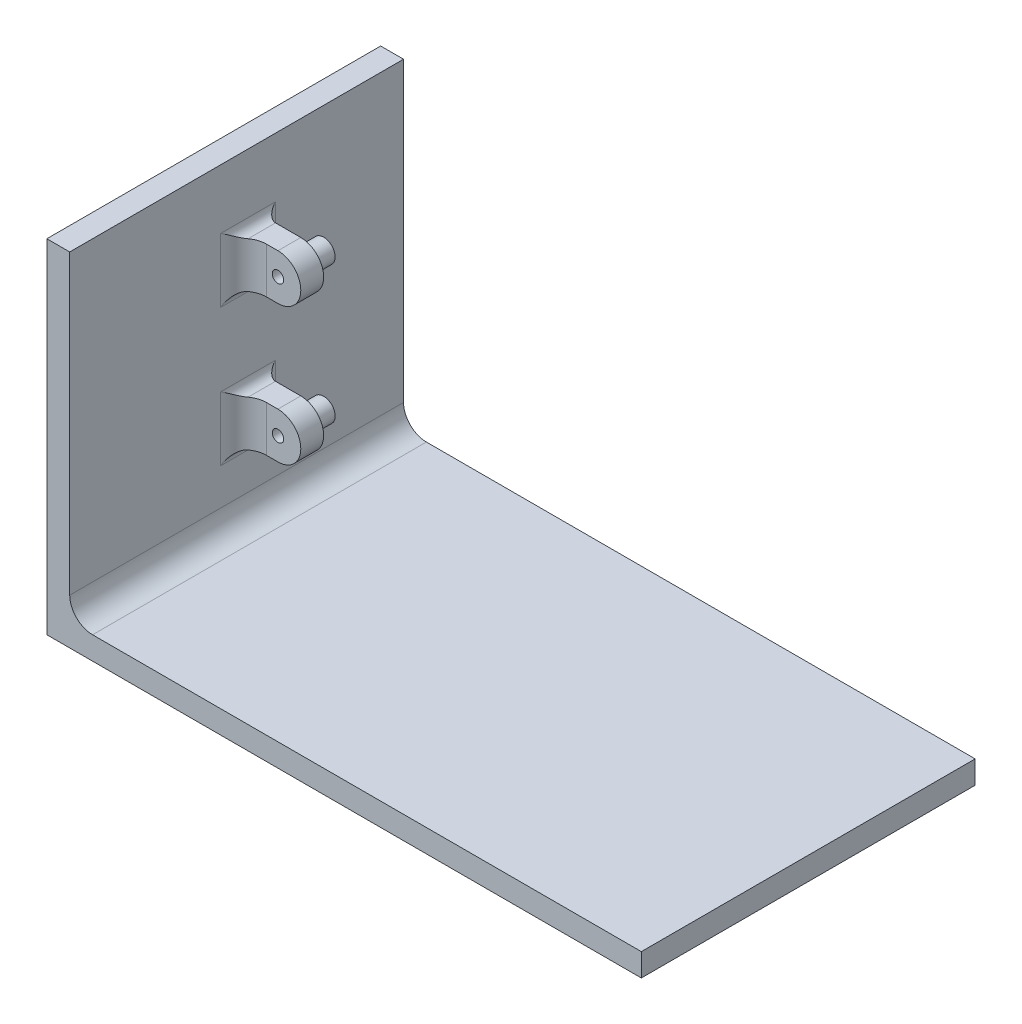
from build123d import *

# Parameters (mm, degrees)
SCHIZZO1_W                   = 5
SCHIZZO1_H                   = 70
ESTRUSIONE_ESTRUSIONE1_DEPTH = 70
ESTRUSIONE_ESTRUSIONE2_START = -35
ESTRUSIONE_ESTRUSIONE2_DEPTH = 5
SCHIZZO3_R                   = 2.5
ESTRUSIONE_ESTRUSIONE3_DEPTH = 5
SCHIZZO4_W                   = 130
SCHIZZO4_H                   = 70
ESTRUSIONE_ESTRUSIONE4_DEPTH = 5
SCHIZZO5_R                   = 1.25
TAGLIO_ESTRUSIONE1_DEPTH     = 46
ESTRUSIONE_ESTRUSIONE5_DEPTH = 3
RACCORDO1_R                  = 5
RACCORDO2_R                  = 5
RACCORDO3_R                  = 2
RACCORDO4_R                  = 2
TAGLIO_ESTRUSIONE2_REACH     = 75


with BuildPart() as part:
    # Schizzo1 → Estrusione-Estrusione1 (new body)
    with BuildSketch(Plane.XY):
        with Locations((-2.5, 35)):
            Rectangle(SCHIZZO1_W, SCHIZZO1_H)
    extrude(amount=ESTRUSIONE_ESTRUSIONE1_DEPTH)

    # Schizzo2 → Estrusione-Estrusione2 (add)
    with BuildSketch(Plane.XY.offset(70).offset(ESTRUSIONE_ESTRUSIONE2_START)):
        with BuildLine():
            Line((0, 50), (0, 45))
            Line((0, 45), (7.531619243, 45))
            ThreePointArc((7.531619243, 45), (12.531619243, 50), (7.531619243, 55))
            Line((7.531619243, 55), (0, 55))
            Line((0, 55), (0, 50))
        make_face()
        with BuildLine():
            Line((0, 20), (0, 15))
            Line((0, 15), (7.531619243, 15))
            ThreePointArc((7.531619243, 15), (12.531619243, 20), (7.531619243, 25))
            Line((7.531619243, 25), (0, 25))
            Line((0, 25), (0, 20))
        make_face()
    extrude(amount=-ESTRUSIONE_ESTRUSIONE2_DEPTH)

    # Schizzo3 → Estrusione-Estrusione3 (add)
    with BuildSketch(Plane(origin=(0, 0, 30), x_dir=(-1, 0, 0), z_dir=(0, 0, -1))):
        with Locations((-7.547600082, 50.061310314)):
            Circle(SCHIZZO3_R)
        with Locations((-7.547600082, 19.939772921)):
            Circle(SCHIZZO3_R)
    extrude(amount=ESTRUSIONE_ESTRUSIONE3_DEPTH)

    # Schizzo4 → Estrusione-Estrusione4 (add)
    with BuildSketch(Plane.XZ):
        with Locations((60, 35)):
            Rectangle(SCHIZZO4_W, SCHIZZO4_H)
    extrude(amount=ESTRUSIONE_ESTRUSIONE4_DEPTH)

    # Schizzo5 → Taglio-Estrusione1 (cut, through all)
    with BuildSketch(Plane(origin=(0, 0, 25), x_dir=(-1, 0, 0), z_dir=(0, 0, -1))):
        with Locations((-7.547600082, 50.061310314)):
            Circle(SCHIZZO5_R)
        with Locations((-7.547600082, 19.939772921)):
            Circle(SCHIZZO5_R)
    extrude(amount=-TAGLIO_ESTRUSIONE1_DEPTH, mode=Mode.SUBTRACT)

    # Schizzo6 → Estrusione-Estrusione5 (add)
    with BuildSketch(Plane.XY.offset(70)):
        Polygon((125, 0), (0, 0), (0, 70), (-5, 70), (-5, -5), (125, -5), align=None)
        Polygon((0, 70), (125, 0), (0, 0), align=None)
    extrude(amount=ESTRUSIONE_ESTRUSIONE5_DEPTH)

    # Raccordo1
    raccordo1_edges = [part.edges().sort_by_distance(p)[0] for p in [
        (0, 35, 70),
        (62.5, 0, 70),
        (0, 0, 35),
    ]]
    fillet(raccordo1_edges, radius=RACCORDO1_R)

    # Raccordo2
    raccordo2_edges = [part.edges().sort_by_distance(p)[0] for p in [
        (0, 50, 35),
        (0, 20, 35),
    ]]
    fillet(raccordo2_edges, radius=RACCORDO2_R)

    # Raccordo3
    raccordo3_edges = [part.edges().sort_by_distance(p)[0] for p in [
        (0, 50, 30),
        (0, 20, 30),
    ]]
    fillet(raccordo3_edges, radius=RACCORDO3_R)

    # Raccordo4
    raccordo4_edges = [part.edges().sort_by_distance(p)[0] for p in [
        (0, 25, 32.5),
        (0, 15, 32.5),
        (0, 45, 32.5),
        (0, 55, 32.5),
    ]]
    fillet(raccordo4_edges, radius=RACCORDO4_R)

    # Schizzo7 → Taglio-Estrusione2 (cut, up to next)
    with BuildSketch(Plane(origin=(0, 0, 73), x_dir=(-1, 0, 0), z_dir=(0, 0, -1)), mode=Mode.PRIVATE) as taglio_estrusione2_sk1:
        with BuildLine():
            ThreePointArc((-5, 0), (-1.464466094, 1.464466094), (0, 5))
            Line((0, 5), (0, 70))
            Line((0, 70), (-125, 0))
            Line((-125, 0), (-5, 0))
        make_face()
    taglio_estrusione2_tool1 = extrude(taglio_estrusione2_sk1.sketch, amount=TAGLIO_ESTRUSIONE2_REACH, mode=Mode.PRIVATE) & part.part
    add(taglio_estrusione2_tool1.solids().sort_by_distance((41.716454, 23.360611, 73))[0], mode=Mode.SUBTRACT)


solid = part.part
